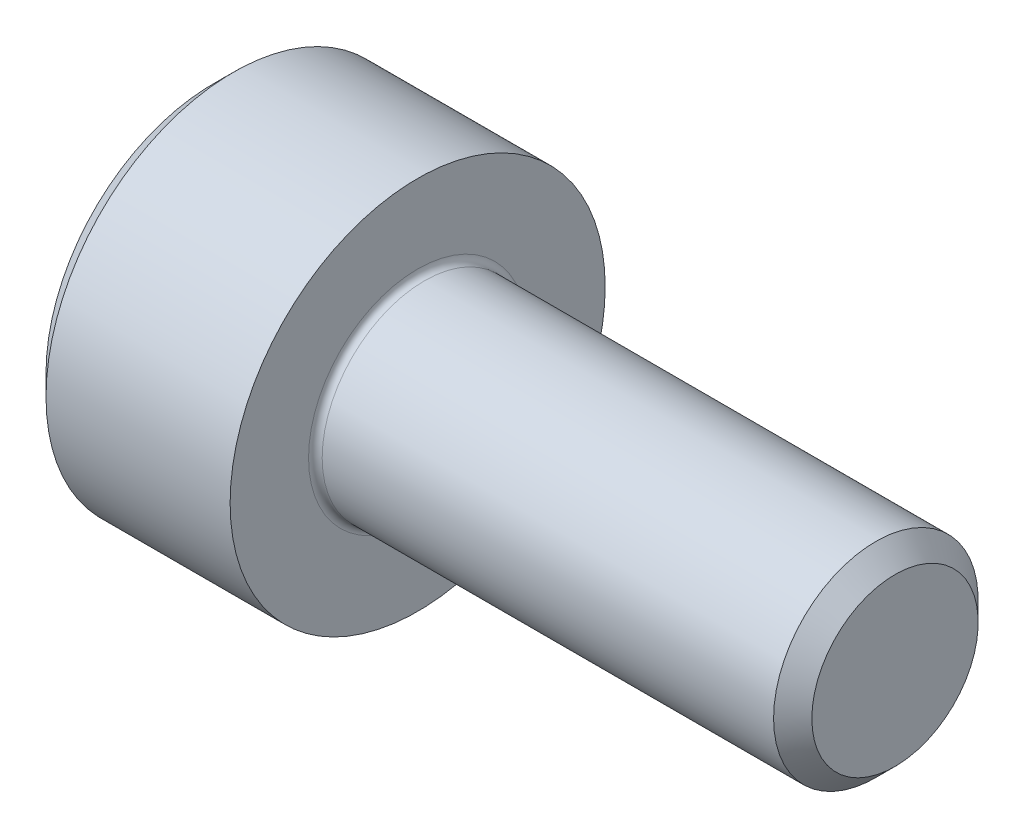
from build123d import *

# Parameters (mm, degrees)
FILLET1_R   = 0.1
HEX_2_DEPTH = 1.3


with BuildPart() as part:
    # BodySke → Base-Revolve (revolve)
    with BuildSketch(Plane.XY):
        Polygon((0, 0), (0, 2.45), (0.3, 2.75), (3, 2.75), (3, 1.5), (9.7195, 1.5), (10, 1.2195), (10, 0), align=None)
    revolve(axis=Axis((-31.75, 0, 0), (1, 0, 0)))

    # Fillet1
    fillet1_edges = [part.edges().sort_by_distance(p)[0] for p in [
        (3, -1.5, 0),
    ]]
    fillet(fillet1_edges, radius=FILLET1_R)

    # Sketch2 → Hex-PreBroach (revolve, cut)
    with BuildSketch(Plane.XY):
        Polygon((0, 1.28), (1.3, 1.28), (2.039008345, 0), (0, 0), align=None)
    revolve(axis=Axis((0, 0, 0), (1, 0, 0)), mode=Mode.SUBTRACT)

    # Sketch3 → Hex 2 (cut)
    with BuildSketch(Plane(origin=(0, 0, 0), x_dir=(0, 0.5, 0.866025404), z_dir=(-1, 0, 0))):
        Polygon((0.739008345, 1.28), (-0.739008345, 1.28), (-1.478016689, 0), (-0.739008345, -1.28), (0.739008345, -1.28), (1.478016689, 0), align=None)
    extrude(amount=-HEX_2_DEPTH, mode=Mode.SUBTRACT)


solid = part.part
